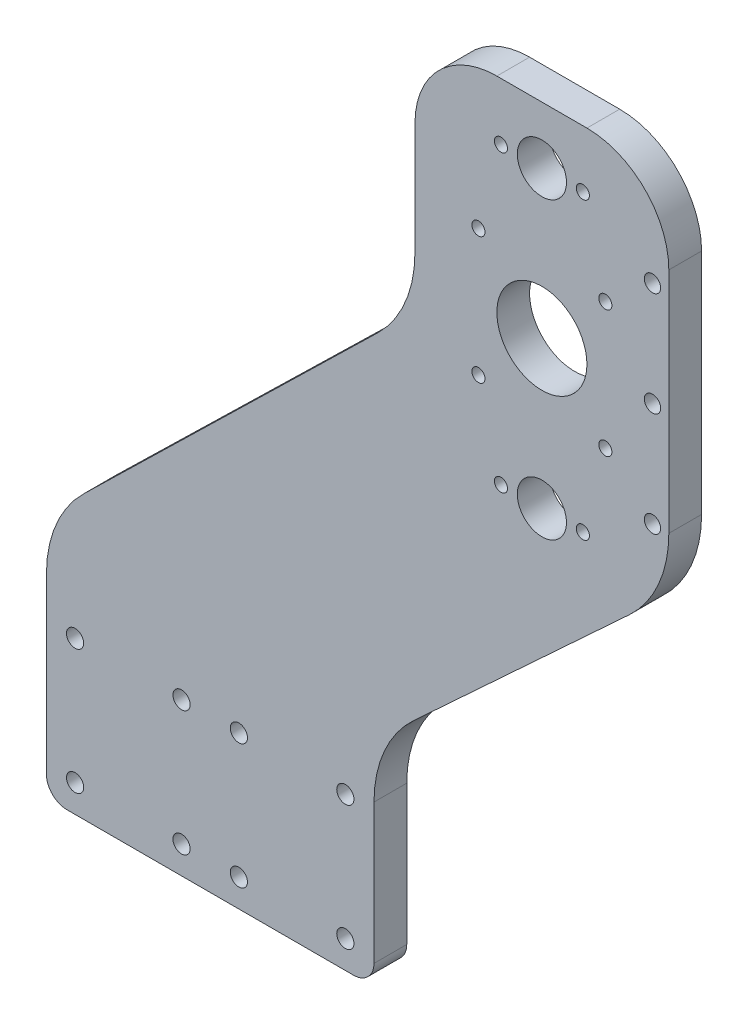
from build123d import *

# Parameters (mm, degrees)
SKETCH1_R           = 2.1
SKETCH1_R_2         = 6
SKETCH1_R_3         = 11
SKETCH1_R_4         = 1.6
SKETCH1_R_5         = 2
BOSS_EXTRUDE1_DEPTH = 8


with BuildPart() as part:
    # Sketch1 → Boss-Extrude1 (new body)
    with BuildSketch(Plane.XY):
        with BuildLine():
            Line((-58.658661762, -94.325772402), (11.341338238, -94.325772402))
            ThreePointArc((11.341338238, -94.325772402), (14.876872144, -92.861306308), (16.341338238, -89.325772402))
            Line((16.341338238, -89.325772402), (16.341338238, -55.206132823))
            ThreePointArc((16.341338238, -55.206132823), (18.853727353, -43.188177597), (25.970088092, -33.18314103))
            Line((25.970088092, -33.18314103), (78.712588384, 15.603630397))
            ThreePointArc((78.712588384, 15.603630397), (85.828949123, 25.608666964), (88.341338238, 37.62662219))
            Line((88.341338238, 37.62662219), (88.341338238, 93.338561628))
            ThreePointArc((88.341338238, 93.338561628), (82.483473862, 107.480697252), (68.341338238, 113.338561628))
            Line((68.341338238, 113.338561628), (46.341338238, 113.338561628))
            ThreePointArc((46.341338238, 113.338561628), (32.199202614, 107.480697252), (26.341338238, 93.338561628))
            Line((26.341338238, 93.338561628), (26.341338238, 65.996620638))
            ThreePointArc((26.341338238, 65.996620638), (23.98166612, 54.334190592), (17.273853267, 44.506394613))
            Line((17.273853267, 44.506394613), (-54.591176791, -25.493605387))
            ThreePointArc((-54.591176791, -25.493605387), (-61.298989644, -35.321401365), (-63.658661762, -46.983831411))
            Line((-63.658661762, -46.983831411), (-63.658661762, -89.325772402))
            ThreePointArc((-63.658661762, -89.325772402), (-62.194195668, -92.861306308), (-58.658661762, -94.325772402))
        make_face()
        with Locations((-56.658661762, -57.075772402)):
            Circle(SKETCH1_R, mode=Mode.SUBTRACT)
        with Locations((-30.658661762, -57.075772402)):
            Circle(SKETCH1_R, mode=Mode.SUBTRACT)
        with Locations((-30.658661762, -87.575772402)):
            Circle(SKETCH1_R, mode=Mode.SUBTRACT)
        with Locations((-56.658661762, -87.575772402)):
            Circle(SKETCH1_R, mode=Mode.SUBTRACT)
        with Locations((9.341338238, -87.575772402)):
            Circle(SKETCH1_R, mode=Mode.SUBTRACT)
        with Locations((-16.658661762, -87.575772402)):
            Circle(SKETCH1_R, mode=Mode.SUBTRACT)
        with Locations((-16.658661762, -57.075772402)):
            Circle(SKETCH1_R, mode=Mode.SUBTRACT)
        with Locations((9.341338238, -57.075772402)):
            Circle(SKETCH1_R, mode=Mode.SUBTRACT)
        with Locations((57.341338238, 99.338561628)):
            Circle(SKETCH1_R_2, mode=Mode.SUBTRACT)
        with Locations((57.341338238, 27.398561628)):
            Circle(SKETCH1_R_2, mode=Mode.SUBTRACT)
        with Locations((57.341338238, 63.368561628)):
            Circle(SKETCH1_R_3, mode=Mode.SUBTRACT)
        with Locations((41.841338238, 78.868561628)):
            Circle(SKETCH1_R_4, mode=Mode.SUBTRACT)
        with Locations((72.841338238, 78.868561628)):
            Circle(SKETCH1_R_4, mode=Mode.SUBTRACT)
        with Locations((72.841338238, 47.868561628)):
            Circle(SKETCH1_R_4, mode=Mode.SUBTRACT)
        with Locations((41.841338238, 47.868561628)):
            Circle(SKETCH1_R_4, mode=Mode.SUBTRACT)
        with Locations((84.341338238, 37.62662219)):
            Circle(SKETCH1_R_5, mode=Mode.SUBTRACT)
        with Locations((84.351781192, 88.518513838)):
            Circle(SKETCH1_R_5, mode=Mode.SUBTRACT)
        with Locations((47.341338238, 99.338561628)):
            Circle(SKETCH1_R_4, mode=Mode.SUBTRACT)
        with Locations((47.341338238, 27.398561628)):
            Circle(SKETCH1_R_4, mode=Mode.SUBTRACT)
        with Locations((67.341338238, 99.338561628)):
            Circle(SKETCH1_R_4, mode=Mode.SUBTRACT)
        with Locations((67.341338238, 27.398561628)):
            Circle(SKETCH1_R_4, mode=Mode.SUBTRACT)
        with Locations((84.346559715, 63.072568014)):
            Circle(SKETCH1_R_5, mode=Mode.SUBTRACT)
    extrude(amount=BOSS_EXTRUDE1_DEPTH)


solid = part.part
